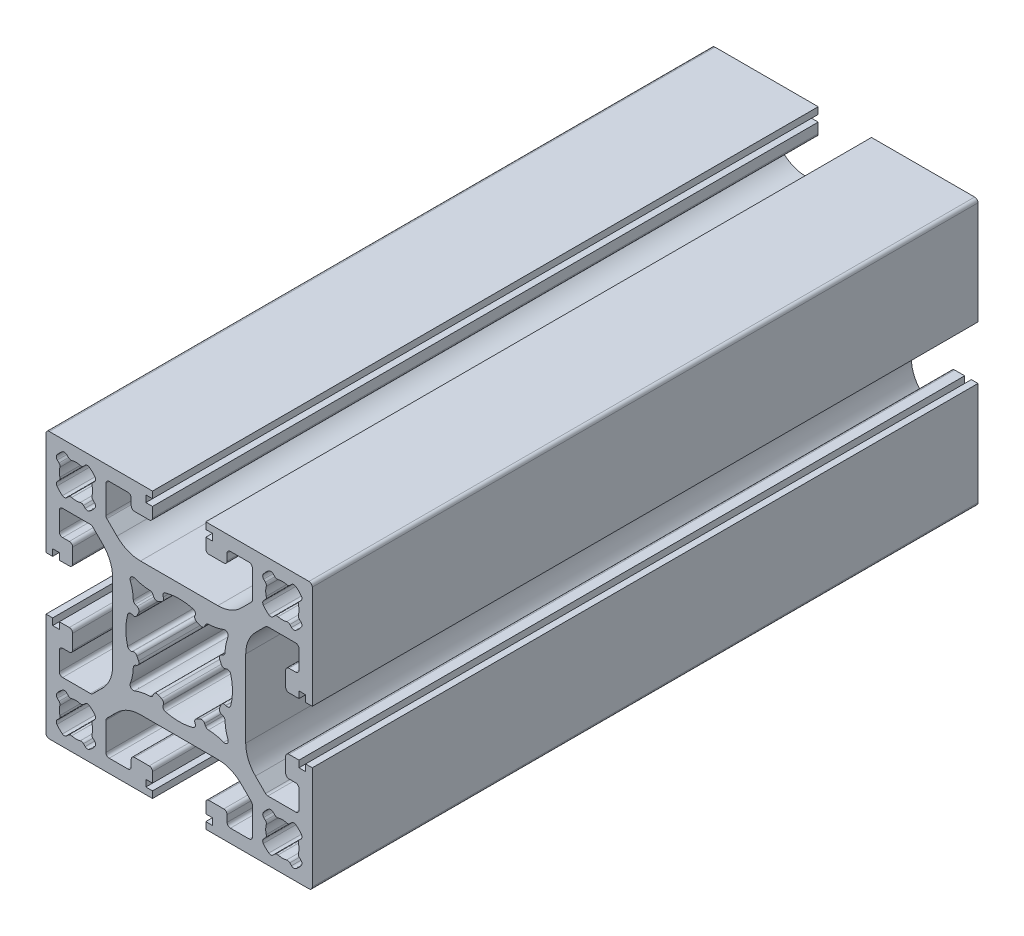
from build123d import *

# Parameters (mm, degrees)
EXTRUDE1_DEPTH = 100


with BuildPart() as part:
    # Sketch1 → Extrude1 (new body)
    with BuildSketch(Plane.XY):
        with BuildLine():
            Line((11, 17.5), (11, 13.328427125))
            ThreePointArc((11, 13.328427125), (10.961939766, 13.137085409), (10.853553391, 12.974873734))
            Line((10.853553391, 12.974873734), (9.343145751, 11.464466094))
            ThreePointArc((9.343145751, 11.464466094), (7.721029006, 10.380602337), (5.807611845, 10))
            Line((5.807611845, 10), (-5.807611845, 10))
            ThreePointArc((-5.807611845, 10), (-7.721029006, 10.380602337), (-9.343145751, 11.464466094))
            Line((-9.343145751, 11.464466094), (-10.853553391, 12.974873734))
            ThreePointArc((-10.853553391, 12.974873734), (-10.961939766, 13.137085409), (-11, 13.328427125))
            Line((-11, 13.328427125), (-11, 17.5))
            ThreePointArc((-11, 17.5), (-10.853553391, 17.853553391), (-10.5, 18))
            Line((-10.5, 18), (-7.7, 18))
            ThreePointArc((-7.7, 18), (-7.346446609, 17.853553391), (-7.2, 17.5))
            Line((-7.2, 17.5), (-7.2, 16.5))
            ThreePointArc((-7.2, 16.5), (-7.053553391, 16.146446609), (-6.7, 16))
            Line((-6.7, 16), (-4.5, 16))
            ThreePointArc((-4.5, 16), (-4.146446609, 16.146446609), (-4, 16.5))
            Line((-4, 16.5), (-4, 18))
            Line((-4, 18), (-5, 18))
            Line((-5, 18), (-5, 19))
            Line((-5, 19), (-4, 19))
            Line((-4, 19), (-4, 20))
            Line((-4, 20), (-19.5, 20))
            ThreePointArc((-19.5, 20), (-19.853553391, 19.853553391), (-20, 19.5))
            Line((-20, 19.5), (-20, 4.5))
            Line((-20, 4.5), (-20, 4))
            Line((-20, 4), (-19.5, 4))
            Line((-19.5, 4), (-19, 4))
            Line((-19, 4), (-19, 5))
            Line((-19, 5), (-18, 5))
            Line((-18, 5), (-18, 4))
            Line((-18, 4), (-16.5, 4))
            ThreePointArc((-16.5, 4), (-16.146446609, 4.146446609), (-16, 4.5))
            Line((-16, 4.5), (-16, 6.7))
            ThreePointArc((-16, 6.7), (-16.146446609, 7.053553391), (-16.5, 7.2))
            Line((-16.5, 7.2), (-17.5, 7.2))
            ThreePointArc((-17.5, 7.2), (-17.853553391, 7.346446609), (-18, 7.7))
            Line((-18, 7.7), (-18, 10.5))
            ThreePointArc((-18, 10.5), (-17.853553391, 10.853553391), (-17.5, 11))
            Line((-17.5, 11), (-16, 11))
            Line((-16, 11), (-13.328427125, 11))
            ThreePointArc((-13.328427125, 11), (-13.137085409, 10.961939766), (-12.974873734, 10.853553391))
            Line((-12.974873734, 10.853553391), (-11.464466094, 9.343145751))
            ThreePointArc((-11.464466094, 9.343145751), (-10.380602337, 7.721029006), (-10, 5.807611845))
            Line((-10, 5.807611845), (-10, -5.807611845))
            ThreePointArc((-10, -5.807611845), (-10.380602337, -7.721029006), (-11.464466094, -9.343145751))
            Line((-11.464466094, -9.343145751), (-12.974873734, -10.853553391))
            ThreePointArc((-12.974873734, -10.853553391), (-13.137085409, -10.961939766), (-13.328427125, -11))
            Line((-13.328427125, -11), (-16, -11))
            Line((-16, -11), (-17.5, -11))
            ThreePointArc((-17.5, -11), (-17.853553391, -10.853553391), (-18, -10.5))
            Line((-18, -10.5), (-18, -7.7))
            ThreePointArc((-18, -7.7), (-17.853553391, -7.346446609), (-17.5, -7.2))
            Line((-17.5, -7.2), (-16.5, -7.2))
            ThreePointArc((-16.5, -7.2), (-16.146446609, -7.053553391), (-16, -6.7))
            Line((-16, -6.7), (-16, -4.5))
            ThreePointArc((-16, -4.5), (-16.146446609, -4.146446609), (-16.5, -4))
            Line((-16.5, -4), (-18, -4))
            Line((-18, -4), (-18, -5))
            Line((-18, -5), (-19, -5))
            Line((-19, -5), (-19, -4))
            Line((-19, -4), (-19.5, -4))
            Line((-19.5, -4), (-20, -4))
            Line((-20, -4), (-20, -4.5))
            Line((-20, -4.5), (-20, -19.5))
            ThreePointArc((-20, -19.5), (-19.853553391, -19.853553391), (-19.5, -20))
            Line((-19.5, -20), (-4, -20))
            Line((-4, -20), (-4, -19))
            Line((-4, -19), (-5, -19))
            Line((-5, -19), (-5, -18))
            Line((-5, -18), (-4, -18))
            Line((-4, -18), (-4, -16.5))
            ThreePointArc((-4, -16.5), (-4.146446609, -16.146446609), (-4.5, -16))
            Line((-4.5, -16), (-6.7, -16))
            ThreePointArc((-6.7, -16), (-7.053553391, -16.146446609), (-7.2, -16.5))
            Line((-7.2, -16.5), (-7.2, -17.5))
            ThreePointArc((-7.2, -17.5), (-7.346446609, -17.853553391), (-7.7, -18))
            Line((-7.7, -18), (-10.5, -18))
            ThreePointArc((-10.5, -18), (-10.853553391, -17.853553391), (-11, -17.5))
            Line((-11, -17.5), (-11, -13.328427125))
            ThreePointArc((-11, -13.328427125), (-10.961939766, -13.137085409), (-10.853553391, -12.974873734))
            Line((-10.853553391, -12.974873734), (-9.343145751, -11.464466094))
            ThreePointArc((-9.343145751, -11.464466094), (-7.721029006, -10.380602337), (-5.807611845, -10))
            Line((-5.807611845, -10), (5.807611845, -10))
            ThreePointArc((5.807611845, -10), (7.721029006, -10.380602337), (9.343145751, -11.464466094))
            Line((9.343145751, -11.464466094), (10.853553391, -12.974873734))
            ThreePointArc((10.853553391, -12.974873734), (10.961939766, -13.137085409), (11, -13.328427125))
            Line((11, -13.328427125), (11, -17.5))
            ThreePointArc((11, -17.5), (10.853553391, -17.853553391), (10.5, -18))
            Line((10.5, -18), (7.7, -18))
            ThreePointArc((7.7, -18), (7.346446609, -17.853553391), (7.2, -17.5))
            Line((7.2, -17.5), (7.2, -16.5))
            ThreePointArc((7.2, -16.5), (7.053553391, -16.146446609), (6.7, -16))
            Line((6.7, -16), (4.5, -16))
            ThreePointArc((4.5, -16), (4.146446609, -16.146446609), (4, -16.5))
            Line((4, -16.5), (4, -18))
            Line((4, -18), (5, -18))
            Line((5, -18), (5, -19))
            Line((5, -19), (4, -19))
            Line((4, -19), (4, -20))
            Line((4, -20), (19.5, -20))
            ThreePointArc((19.5, -20), (19.853553391, -19.853553391), (20, -19.5))
            Line((20, -19.5), (20, -4.5))
            Line((20, -4.5), (20, -4))
            Line((20, -4), (19.5, -4))
            Line((19.5, -4), (19, -4))
            Line((19, -4), (19, -5))
            Line((19, -5), (18, -5))
            Line((18, -5), (18, -4))
            Line((18, -4), (16.5, -4))
            ThreePointArc((16.5, -4), (16.146446609, -4.146446609), (16, -4.5))
            Line((16, -4.5), (16, -6.7))
            ThreePointArc((16, -6.7), (16.146446609, -7.053553391), (16.5, -7.2))
            Line((16.5, -7.2), (17.5, -7.2))
            ThreePointArc((17.5, -7.2), (17.853553391, -7.346446609), (18, -7.7))
            Line((18, -7.7), (18, -10.5))
            ThreePointArc((18, -10.5), (17.853553391, -10.853553391), (17.5, -11))
            Line((17.5, -11), (16, -11))
            Line((16, -11), (13.328427125, -11))
            ThreePointArc((13.328427125, -11), (13.137085409, -10.961939766), (12.974873734, -10.853553391))
            Line((12.974873734, -10.853553391), (11.464466094, -9.343145751))
            ThreePointArc((11.464466094, -9.343145751), (10.380602337, -7.721029006), (10, -5.807611845))
            Line((10, -5.807611845), (10, 5.807611845))
            ThreePointArc((10, 5.807611845), (10.380602337, 7.721029006), (11.464466094, 9.343145751))
            Line((11.464466094, 9.343145751), (12.974873734, 10.853553391))
            ThreePointArc((12.974873734, 10.853553391), (13.137085409, 10.961939766), (13.328427125, 11))
            Line((13.328427125, 11), (16, 11))
            Line((16, 11), (17.5, 11))
            ThreePointArc((17.5, 11), (17.853553391, 10.853553391), (18, 10.5))
            Line((18, 10.5), (18, 7.7))
            ThreePointArc((18, 7.7), (17.853553391, 7.346446609), (17.5, 7.2))
            Line((17.5, 7.2), (16.5, 7.2))
            ThreePointArc((16.5, 7.2), (16.146446609, 7.053553391), (16, 6.7))
            Line((16, 6.7), (16, 4.5))
            ThreePointArc((16, 4.5), (16.146446609, 4.146446609), (16.5, 4))
            Line((16.5, 4), (18, 4))
            Line((18, 4), (18, 5))
            Line((18, 5), (19, 5))
            Line((19, 5), (19, 4))
            Line((19, 4), (19.5, 4))
            Line((19.5, 4), (20, 4))
            Line((20, 4), (20, 4.5))
            Line((20, 4.5), (20, 19.5))
            ThreePointArc((20, 19.5), (19.853553391, 19.853553391), (19.5, 20))
            Line((19.5, 20), (4, 20))
            Line((4, 20), (4, 19))
            Line((4, 19), (5, 19))
            Line((5, 19), (5, 18))
            Line((5, 18), (4, 18))
            Line((4, 18), (4, 16.5))
            ThreePointArc((4, 16.5), (4.146446609, 16.146446609), (4.5, 16))
            Line((4.5, 16), (6.7, 16))
            ThreePointArc((6.7, 16), (7.053553391, 16.146446609), (7.2, 16.5))
            Line((7.2, 16.5), (7.2, 17.5))
            ThreePointArc((7.2, 17.5), (7.346446609, 17.853553391), (7.7, 18))
            Line((7.7, 18), (10.5, 18))
            ThreePointArc((10.5, 18), (10.853553391, 17.853553391), (11, 17.5))
        make_face()
        with BuildLine():
            Line((-3.955481277, 6.589595707), (-3.828701916, 6.317716489))
            ThreePointArc((-3.828701916, 6.317716489), (-3.536931765, 6.055786476), (-3.145918905, 6.084874217))
            ThreePointArc((-3.145918905, 6.084874217), (-2.894935093, 6.208208341), (-2.639126388, 6.321195449))
            ThreePointArc((-2.639126388, 6.321195449), (-2.365505664, 6.602031438), (-2.378609457, 6.993905708))
            Line((-2.378609457, 6.993905708), (-2.396612625, 7.032513628))
            ThreePointArc((-2.396612625, 7.032513628), (-2.396646397, 7.455059452), (-2.073022647, 7.726744276))
            ThreePointArc((-2.073022647, 7.726744276), (0, 8), (2.073022647, 7.726744276))
            ThreePointArc((2.073022647, 7.726744276), (2.396646397, 7.455059452), (2.396612625, 7.032513628))
            Line((2.396612625, 7.032513628), (2.378609457, 6.993905708))
            ThreePointArc((2.378609457, 6.993905708), (2.365505664, 6.602031438), (2.639126388, 6.321195449))
            ThreePointArc((2.639126388, 6.321195449), (2.894935093, 6.208208341), (3.145918905, 6.084874217))
            ThreePointArc((3.145918905, 6.084874217), (3.536931765, 6.055786476), (3.828701916, 6.317716489))
            Line((3.828701916, 6.317716489), (3.955481277, 6.589595707))
            ThreePointArc((3.955481277, 6.589595707), (4.133992703, 6.796104137), (4.394360834, 6.878082778))
            ThreePointArc((4.394360834, 6.878082778), (5.563636578, 7.01042661), (6.694221632, 7.336767065))
            ThreePointArc((6.694221632, 7.336767065), (7.225849065, 7.223762843), (7.340283605, 6.692441455))
            ThreePointArc((7.340283605, 6.692441455), (7.017377418, 5.56296621), (6.887896152, 4.395397224))
            ThreePointArc((6.887896152, 4.395397224), (6.806059945, 4.134233802), (6.59898837, 3.955278888))
            Line((6.59898837, 3.955278888), (6.319893727, 3.825428413))
            ThreePointArc((6.319893727, 3.825428413), (6.057684603, 3.533805493), (6.086538329, 3.142698072))
            ThreePointArc((6.086538329, 3.142698072), (6.20973961, 2.891649006), (6.322591322, 2.635780524))
            ThreePointArc((6.322591322, 2.635780524), (6.603204408, 2.362041487), (6.995011811, 2.374836943))
            Line((6.995011811, 2.374836943), (7.043041461, 2.397183029))
            ThreePointArc((7.043041461, 2.397183029), (7.46545934, 2.396911359), (7.736919279, 2.073265813))
            ThreePointArc((7.736919279, 2.073265813), (8.009890827, 0), (7.736919279, -2.073265813))
            ThreePointArc((7.736919279, -2.073265813), (7.46545934, -2.396911359), (7.043041461, -2.397183029))
            Line((7.043041461, -2.397183029), (6.995011811, -2.374836943))
            ThreePointArc((6.995011811, -2.374836943), (6.603204408, -2.362041487), (6.322591322, -2.635780524))
            ThreePointArc((6.322591322, -2.635780524), (6.20973961, -2.891649006), (6.086538329, -3.142698072))
            ThreePointArc((6.086538329, -3.142698072), (6.057684603, -3.533805493), (6.319893727, -3.825428413))
            Line((6.319893727, -3.825428413), (6.59898837, -3.955278888))
            ThreePointArc((6.59898837, -3.955278888), (6.806059945, -4.134233802), (6.887896152, -4.395397224))
            ThreePointArc((6.887896152, -4.395397224), (7.017377418, -5.56296621), (7.340283605, -6.692441455))
            ThreePointArc((7.340283605, -6.692441455), (7.225849065, -7.223762843), (6.694221632, -7.336767065))
            ThreePointArc((6.694221632, -7.336767065), (5.563636578, -7.01042661), (4.394360834, -6.878082778))
            ThreePointArc((4.394360834, -6.878082778), (4.133992703, -6.796104137), (3.955481277, -6.589595707))
            Line((3.955481277, -6.589595707), (3.828701916, -6.317716489))
            ThreePointArc((3.828701916, -6.317716489), (3.536931765, -6.055786476), (3.145918905, -6.084874217))
            ThreePointArc((3.145918905, -6.084874217), (2.894935093, -6.208208341), (2.639126388, -6.321195449))
            ThreePointArc((2.639126388, -6.321195449), (2.365505664, -6.602031438), (2.378609457, -6.993905708))
            Line((2.378609457, -6.993905708), (2.396612625, -7.032513628))
            ThreePointArc((2.396612625, -7.032513628), (2.396646397, -7.455059452), (2.073022647, -7.726744276))
            ThreePointArc((2.073022647, -7.726744276), (0, -8), (-2.073022647, -7.726744276))
            ThreePointArc((-2.073022647, -7.726744276), (-2.396646397, -7.455059452), (-2.396612625, -7.032513628))
            Line((-2.396612625, -7.032513628), (-2.378609457, -6.993905708))
            ThreePointArc((-2.378609457, -6.993905708), (-2.365505664, -6.602031438), (-2.639126388, -6.321195449))
            ThreePointArc((-2.639126388, -6.321195449), (-2.894935093, -6.208208341), (-3.145918905, -6.084874217))
            ThreePointArc((-3.145918905, -6.084874217), (-3.536931765, -6.055786476), (-3.828701916, -6.317716489))
            Line((-3.828701916, -6.317716489), (-3.955481277, -6.589595707))
            ThreePointArc((-3.955481277, -6.589595707), (-4.133992703, -6.796104137), (-4.394360834, -6.878082778))
            ThreePointArc((-4.394360834, -6.878082778), (-5.563636578, -7.01042661), (-6.694221632, -7.336767065))
            ThreePointArc((-6.694221632, -7.336767065), (-7.225849065, -7.223762843), (-7.340283605, -6.692441455))
            ThreePointArc((-7.340283605, -6.692441455), (-7.017377418, -5.56296621), (-6.887896152, -4.395397224))
            ThreePointArc((-6.887896152, -4.395397224), (-6.806059945, -4.134233802), (-6.59898837, -3.955278888))
            Line((-6.59898837, -3.955278888), (-6.319893727, -3.825428413))
            ThreePointArc((-6.319893727, -3.825428413), (-6.057684603, -3.533805493), (-6.086538329, -3.142698072))
            ThreePointArc((-6.086538329, -3.142698072), (-6.20973961, -2.891649006), (-6.322591322, -2.635780524))
            ThreePointArc((-6.322591322, -2.635780524), (-6.603204408, -2.362041487), (-6.995011811, -2.374836943))
            Line((-6.995011811, -2.374836943), (-7.043041461, -2.397183029))
            ThreePointArc((-7.043041461, -2.397183029), (-7.46545934, -2.396911359), (-7.736919279, -2.073265813))
            ThreePointArc((-7.736919279, -2.073265813), (-8.009890827, 0), (-7.736919279, 2.073265813))
            ThreePointArc((-7.736919279, 2.073265813), (-7.46545934, 2.396911359), (-7.043041461, 2.397183029))
            Line((-7.043041461, 2.397183029), (-6.995011811, 2.374836943))
            ThreePointArc((-6.995011811, 2.374836943), (-6.603204408, 2.362041487), (-6.322591322, 2.635780524))
            ThreePointArc((-6.322591322, 2.635780524), (-6.20973961, 2.891649006), (-6.086538329, 3.142698072))
            ThreePointArc((-6.086538329, 3.142698072), (-6.057684603, 3.533805493), (-6.319893727, 3.825428413))
            Line((-6.319893727, 3.825428413), (-6.59898837, 3.955278888))
            ThreePointArc((-6.59898837, 3.955278888), (-6.806059945, 4.134233802), (-6.887896152, 4.395397224))
            ThreePointArc((-6.887896152, 4.395397224), (-7.017377418, 5.56296621), (-7.340283605, 6.692441455))
            ThreePointArc((-7.340283605, 6.692441455), (-7.225849065, 7.223762843), (-6.694221632, 7.336767065))
            ThreePointArc((-6.694221632, 7.336767065), (-5.563636578, 7.01042661), (-4.394360834, 6.878082778))
            ThreePointArc((-4.394360834, 6.878082778), (-4.133992703, 6.796104137), (-3.955481277, 6.589595707))
        make_face(mode=Mode.SUBTRACT)
        with BuildLine():
            Line((-14.115456715, 18.298756848), (-14.369989474, 18.044224088))
            ThreePointArc((-14.369989474, 18.044224088), (-14.594133342, 17.914814566), (-14.852952387, 17.914814566))
            ThreePointArc((-14.852952387, 17.914814566), (-15.5, 18), (-16.147047613, 17.914814566))
            ThreePointArc((-16.147047613, 17.914814566), (-16.405866658, 17.914814566), (-16.630010526, 18.044224088))
            Line((-16.630010526, 18.044224088), (-16.884543285, 18.298756848))
            ThreePointArc((-16.884543285, 18.298756848), (-17.196283546, 18.443452052), (-17.527779455, 18.352737366))
            ThreePointArc((-17.527779455, 18.352737366), (-17.974873734, 17.974873734), (-18.352737366, 17.527779455))
            ThreePointArc((-18.352737366, 17.527779455), (-18.443452052, 17.196283546), (-18.298756848, 16.884543285))
            Line((-18.298756848, 16.884543285), (-18.044224088, 16.630010526))
            ThreePointArc((-18.044224088, 16.630010526), (-17.914814566, 16.405866658), (-17.914814566, 16.147047613))
            ThreePointArc((-17.914814566, 16.147047613), (-18, 15.5), (-17.914814566, 14.852952387))
            ThreePointArc((-17.914814566, 14.852952387), (-17.914814566, 14.594133342), (-18.044224088, 14.369989474))
            Line((-18.044224088, 14.369989474), (-18.298756848, 14.115456715))
            ThreePointArc((-18.298756848, 14.115456715), (-18.443452052, 13.803716454), (-18.352737366, 13.472220545))
            ThreePointArc((-18.352737366, 13.472220545), (-17.974873734, 13.025126266), (-17.527779455, 12.647262634))
            ThreePointArc((-17.527779455, 12.647262634), (-17.196283546, 12.556547948), (-16.884543285, 12.701243152))
            Line((-16.884543285, 12.701243152), (-16.630010526, 12.955775912))
            ThreePointArc((-16.630010526, 12.955775912), (-16.405866658, 13.085185434), (-16.147047613, 13.085185434))
            ThreePointArc((-16.147047613, 13.085185434), (-15.5, 13), (-14.852952387, 13.085185434))
            ThreePointArc((-14.852952387, 13.085185434), (-14.594133342, 13.085185434), (-14.369989474, 12.955775912))
            Line((-14.369989474, 12.955775912), (-14.115456715, 12.701243152))
            ThreePointArc((-14.115456715, 12.701243152), (-13.803716454, 12.556547948), (-13.472220545, 12.647262634))
            ThreePointArc((-13.472220545, 12.647262634), (-13.025126266, 13.025126266), (-12.647262634, 13.472220545))
            ThreePointArc((-12.647262634, 13.472220545), (-12.556547948, 13.803716454), (-12.701243152, 14.115456715))
            Line((-12.701243152, 14.115456715), (-12.955775912, 14.369989474))
            ThreePointArc((-12.955775912, 14.369989474), (-13.085185434, 14.594133342), (-13.085185434, 14.852952387))
            ThreePointArc((-13.085185434, 14.852952387), (-13, 15.5), (-13.085185434, 16.147047613))
            ThreePointArc((-13.085185434, 16.147047613), (-13.085185434, 16.405866658), (-12.955775912, 16.630010526))
            Line((-12.955775912, 16.630010526), (-12.701243152, 16.884543285))
            ThreePointArc((-12.701243152, 16.884543285), (-12.556547948, 17.196283546), (-12.647262634, 17.527779455))
            ThreePointArc((-12.647262634, 17.527779455), (-13.025126266, 17.974873734), (-13.472220545, 18.352737366))
            ThreePointArc((-13.472220545, 18.352737366), (-13.803716454, 18.443452052), (-14.115456715, 18.298756848))
        make_face(mode=Mode.SUBTRACT)
        with BuildLine():
            Line((14.115456715, 12.701243152), (14.369989474, 12.955775912))
            ThreePointArc((14.369989474, 12.955775912), (14.594133342, 13.085185434), (14.852952387, 13.085185434))
            ThreePointArc((14.852952387, 13.085185434), (15.5, 13), (16.147047613, 13.085185434))
            ThreePointArc((16.147047613, 13.085185434), (16.405866658, 13.085185434), (16.630010526, 12.955775912))
            Line((16.630010526, 12.955775912), (16.884543285, 12.701243152))
            ThreePointArc((16.884543285, 12.701243152), (17.196283546, 12.556547948), (17.527779455, 12.647262634))
            ThreePointArc((17.527779455, 12.647262634), (17.974873734, 13.025126266), (18.352737366, 13.472220545))
            ThreePointArc((18.352737366, 13.472220545), (18.443452052, 13.803716454), (18.298756848, 14.115456715))
            Line((18.298756848, 14.115456715), (18.044224088, 14.369989474))
            ThreePointArc((18.044224088, 14.369989474), (17.914814566, 14.594133342), (17.914814566, 14.852952387))
            ThreePointArc((17.914814566, 14.852952387), (18, 15.5), (17.914814566, 16.147047613))
            ThreePointArc((17.914814566, 16.147047613), (17.914814566, 16.405866658), (18.044224088, 16.630010526))
            Line((18.044224088, 16.630010526), (18.298756848, 16.884543285))
            ThreePointArc((18.298756848, 16.884543285), (18.443452052, 17.196283546), (18.352737366, 17.527779455))
            ThreePointArc((18.352737366, 17.527779455), (17.974873734, 17.974873734), (17.527779455, 18.352737366))
            ThreePointArc((17.527779455, 18.352737366), (17.196283546, 18.443452052), (16.884543285, 18.298756848))
            Line((16.884543285, 18.298756848), (16.630010526, 18.044224088))
            ThreePointArc((16.630010526, 18.044224088), (16.405866658, 17.914814566), (16.147047613, 17.914814566))
            ThreePointArc((16.147047613, 17.914814566), (15.5, 18), (14.852952387, 17.914814566))
            ThreePointArc((14.852952387, 17.914814566), (14.594133342, 17.914814566), (14.369989474, 18.044224088))
            Line((14.369989474, 18.044224088), (14.115456715, 18.298756848))
            ThreePointArc((14.115456715, 18.298756848), (13.803716454, 18.443452052), (13.472220545, 18.352737366))
            ThreePointArc((13.472220545, 18.352737366), (13.025126266, 17.974873734), (12.647262634, 17.527779455))
            ThreePointArc((12.647262634, 17.527779455), (12.556547948, 17.196283546), (12.701243152, 16.884543285))
            Line((12.701243152, 16.884543285), (12.955775912, 16.630010526))
            ThreePointArc((12.955775912, 16.630010526), (13.085185434, 16.405866658), (13.085185434, 16.147047613))
            ThreePointArc((13.085185434, 16.147047613), (13, 15.5), (13.085185434, 14.852952387))
            ThreePointArc((13.085185434, 14.852952387), (13.085185434, 14.594133342), (12.955775912, 14.369989474))
            Line((12.955775912, 14.369989474), (12.701243152, 14.115456715))
            ThreePointArc((12.701243152, 14.115456715), (12.556547948, 13.803716454), (12.647262634, 13.472220545))
            ThreePointArc((12.647262634, 13.472220545), (13.025126266, 13.025126266), (13.472220545, 12.647262634))
            ThreePointArc((13.472220545, 12.647262634), (13.803716454, 12.556547948), (14.115456715, 12.701243152))
        make_face(mode=Mode.SUBTRACT)
        with BuildLine():
            Line((14.115456715, -18.298756848), (14.369989474, -18.044224088))
            ThreePointArc((14.369989474, -18.044224088), (14.594133342, -17.914814566), (14.852952387, -17.914814566))
            ThreePointArc((14.852952387, -17.914814566), (15.5, -18), (16.147047613, -17.914814566))
            ThreePointArc((16.147047613, -17.914814566), (16.405866658, -17.914814566), (16.630010526, -18.044224088))
            Line((16.630010526, -18.044224088), (16.884543285, -18.298756848))
            ThreePointArc((16.884543285, -18.298756848), (17.196283546, -18.443452052), (17.527779455, -18.352737366))
            ThreePointArc((17.527779455, -18.352737366), (17.974873734, -17.974873734), (18.352737366, -17.527779455))
            ThreePointArc((18.352737366, -17.527779455), (18.443452052, -17.196283546), (18.298756848, -16.884543285))
            Line((18.298756848, -16.884543285), (18.044224088, -16.630010526))
            ThreePointArc((18.044224088, -16.630010526), (17.914814566, -16.405866658), (17.914814566, -16.147047613))
            ThreePointArc((17.914814566, -16.147047613), (18, -15.5), (17.914814566, -14.852952387))
            ThreePointArc((17.914814566, -14.852952387), (17.914814566, -14.594133342), (18.044224088, -14.369989474))
            Line((18.044224088, -14.369989474), (18.298756848, -14.115456715))
            ThreePointArc((18.298756848, -14.115456715), (18.443452052, -13.803716454), (18.352737366, -13.472220545))
            ThreePointArc((18.352737366, -13.472220545), (17.974873734, -13.025126266), (17.527779455, -12.647262634))
            ThreePointArc((17.527779455, -12.647262634), (17.196283546, -12.556547948), (16.884543285, -12.701243152))
            Line((16.884543285, -12.701243152), (16.630010526, -12.955775912))
            ThreePointArc((16.630010526, -12.955775912), (16.405866658, -13.085185434), (16.147047613, -13.085185434))
            ThreePointArc((16.147047613, -13.085185434), (15.5, -13), (14.852952387, -13.085185434))
            ThreePointArc((14.852952387, -13.085185434), (14.594133342, -13.085185434), (14.369989474, -12.955775912))
            Line((14.369989474, -12.955775912), (14.115456715, -12.701243152))
            ThreePointArc((14.115456715, -12.701243152), (13.803716454, -12.556547948), (13.472220545, -12.647262634))
            ThreePointArc((13.472220545, -12.647262634), (13.025126266, -13.025126266), (12.647262634, -13.472220545))
            ThreePointArc((12.647262634, -13.472220545), (12.556547948, -13.803716454), (12.701243152, -14.115456715))
            Line((12.701243152, -14.115456715), (12.955775912, -14.369989474))
            ThreePointArc((12.955775912, -14.369989474), (13.085185434, -14.594133342), (13.085185434, -14.852952387))
            ThreePointArc((13.085185434, -14.852952387), (13, -15.5), (13.085185434, -16.147047613))
            ThreePointArc((13.085185434, -16.147047613), (13.085185434, -16.405866658), (12.955775912, -16.630010526))
            Line((12.955775912, -16.630010526), (12.701243152, -16.884543285))
            ThreePointArc((12.701243152, -16.884543285), (12.556547948, -17.196283546), (12.647262634, -17.527779455))
            ThreePointArc((12.647262634, -17.527779455), (13.025126266, -17.974873734), (13.472220545, -18.352737366))
            ThreePointArc((13.472220545, -18.352737366), (13.803716454, -18.443452052), (14.115456715, -18.298756848))
        make_face(mode=Mode.SUBTRACT)
        with BuildLine():
            Line((-14.115456715, -12.701243152), (-14.369989474, -12.955775912))
            ThreePointArc((-14.369989474, -12.955775912), (-14.594133342, -13.085185434), (-14.852952387, -13.085185434))
            ThreePointArc((-14.852952387, -13.085185434), (-15.5, -13), (-16.147047613, -13.085185434))
            ThreePointArc((-16.147047613, -13.085185434), (-16.405866658, -13.085185434), (-16.630010526, -12.955775912))
            Line((-16.630010526, -12.955775912), (-16.884543285, -12.701243152))
            ThreePointArc((-16.884543285, -12.701243152), (-17.196283546, -12.556547948), (-17.527779455, -12.647262634))
            ThreePointArc((-17.527779455, -12.647262634), (-17.974873734, -13.025126266), (-18.352737366, -13.472220545))
            ThreePointArc((-18.352737366, -13.472220545), (-18.443452052, -13.803716454), (-18.298756848, -14.115456715))
            Line((-18.298756848, -14.115456715), (-18.044224088, -14.369989474))
            ThreePointArc((-18.044224088, -14.369989474), (-17.914814566, -14.594133342), (-17.914814566, -14.852952387))
            ThreePointArc((-17.914814566, -14.852952387), (-18, -15.5), (-17.914814566, -16.147047613))
            ThreePointArc((-17.914814566, -16.147047613), (-17.914814566, -16.405866658), (-18.044224088, -16.630010526))
            Line((-18.044224088, -16.630010526), (-18.298756848, -16.884543285))
            ThreePointArc((-18.298756848, -16.884543285), (-18.443452052, -17.196283546), (-18.352737366, -17.527779455))
            ThreePointArc((-18.352737366, -17.527779455), (-17.974873734, -17.974873734), (-17.527779455, -18.352737366))
            ThreePointArc((-17.527779455, -18.352737366), (-17.196283546, -18.443452052), (-16.884543285, -18.298756848))
            Line((-16.884543285, -18.298756848), (-16.630010526, -18.044224088))
            ThreePointArc((-16.630010526, -18.044224088), (-16.405866658, -17.914814566), (-16.147047613, -17.914814566))
            ThreePointArc((-16.147047613, -17.914814566), (-15.5, -18), (-14.852952387, -17.914814566))
            ThreePointArc((-14.852952387, -17.914814566), (-14.594133342, -17.914814566), (-14.369989474, -18.044224088))
            Line((-14.369989474, -18.044224088), (-14.115456715, -18.298756848))
            ThreePointArc((-14.115456715, -18.298756848), (-13.803716454, -18.443452052), (-13.472220545, -18.352737366))
            ThreePointArc((-13.472220545, -18.352737366), (-13.025126266, -17.974873734), (-12.647262634, -17.527779455))
            ThreePointArc((-12.647262634, -17.527779455), (-12.556547948, -17.196283546), (-12.701243152, -16.884543285))
            Line((-12.701243152, -16.884543285), (-12.955775912, -16.630010526))
            ThreePointArc((-12.955775912, -16.630010526), (-13.085185434, -16.405866658), (-13.085185434, -16.147047613))
            ThreePointArc((-13.085185434, -16.147047613), (-13, -15.5), (-13.085185434, -14.852952387))
            ThreePointArc((-13.085185434, -14.852952387), (-13.085185434, -14.594133342), (-12.955775912, -14.369989474))
            Line((-12.955775912, -14.369989474), (-12.701243152, -14.115456715))
            ThreePointArc((-12.701243152, -14.115456715), (-12.556547948, -13.803716454), (-12.647262634, -13.472220545))
            ThreePointArc((-12.647262634, -13.472220545), (-13.025126266, -13.025126266), (-13.472220545, -12.647262634))
            ThreePointArc((-13.472220545, -12.647262634), (-13.803716454, -12.556547948), (-14.115456715, -12.701243152))
        make_face(mode=Mode.SUBTRACT)
    extrude(amount=-EXTRUDE1_DEPTH)


solid = part.part
